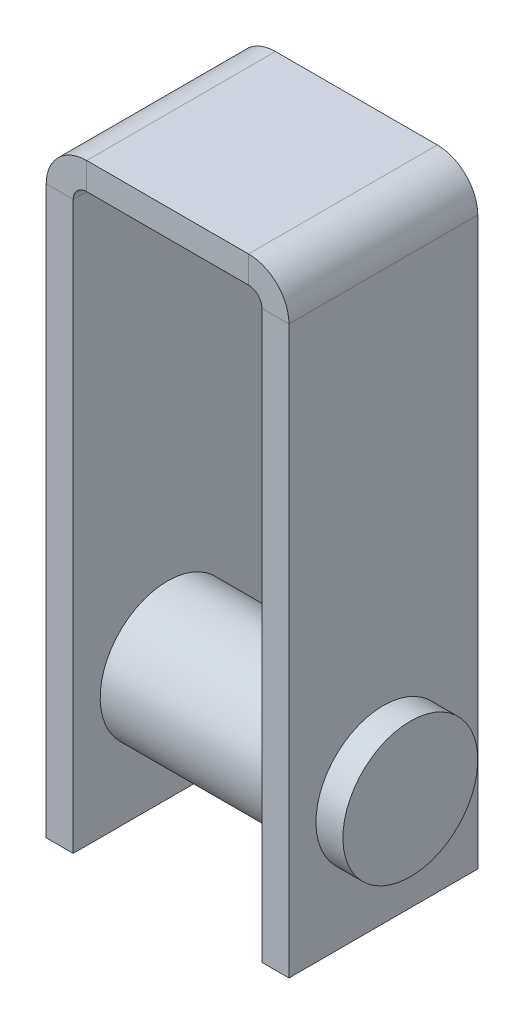
from build123d import *

# Parameters (mm, degrees)
SKETCH2_W                = 70
SKETCH2_H                = 10
SKETCH3_R                = 25
CUT_EXTRUDE1_DEPTH       = 91
SKETCH4_R                = 25
BOSS_EXTRUDE1_DEPTH      = 10
BOSS_EXTRUDE1_DEPTH_BACK = 100


with BuildPart() as part:
    # Sweep1: sweep along a path in Sketch1
    with BuildLine(Plane.XY) as sweep1_path:
        Line((48.354821102, -220), (48.354821102, -10))
        ThreePointArc((48.354821102, -10), (45.425888913, -2.928932188), (38.354821102, 0))
        Line((38.354821102, 0), (-21.645178898, 0))
        ThreePointArc((-21.645178898, 0), (-28.71624671, -2.928932188), (-31.645178898, -10))
        Line((-31.645178898, -10), (-31.645178898, -220))
    # Sketch2 → Sweep1 (sweep)
    with BuildSketch(Plane(origin=(0, 0, 0), x_dir=(0, 0, -1), z_dir=(1, 0, 0))):
        Rectangle(SKETCH2_W, SKETCH2_H)
    sweep(path=sweep1_path.line)

    # Sketch3 → Cut-Extrude1 (cut, through all)
    with BuildSketch(Plane(origin=(53.354821102, 0, 0), x_dir=(0, 0, -1), z_dir=(1, 0, 0))):
        with Locations((0, -175)):
            Circle(SKETCH3_R)
    extrude(amount=-CUT_EXTRUDE1_DEPTH, mode=Mode.SUBTRACT)

    # Sketch4 → Boss-Extrude1 (add, two sides)
    with BuildSketch(Plane(origin=(53.354821102, 0, 0), x_dir=(0, 0, -1), z_dir=(1, 0, 0))) as boss_extrude1_sk:
        with Locations((0, -175)):
            Circle(SKETCH4_R)
    extrude(amount=BOSS_EXTRUDE1_DEPTH)
    extrude(boss_extrude1_sk.sketch, amount=-BOSS_EXTRUDE1_DEPTH_BACK)


solid = part.part
